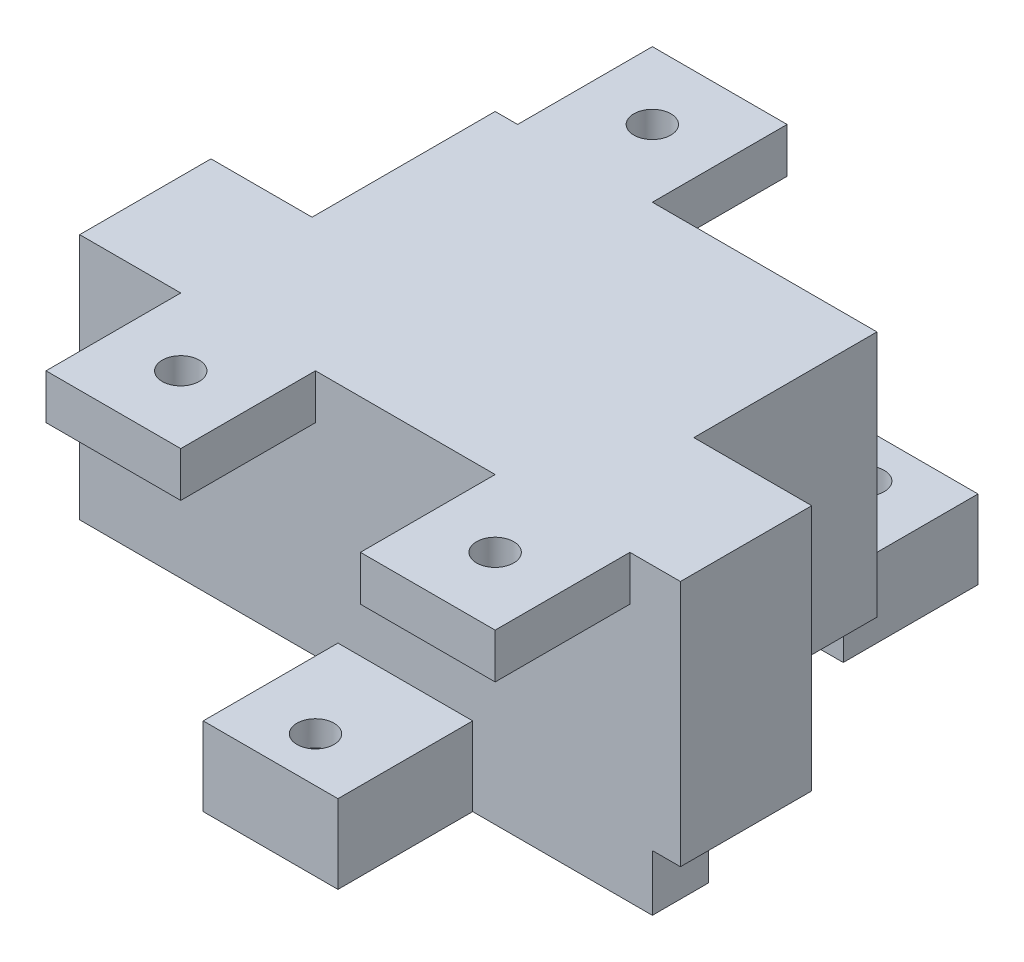
from build123d import *

# Parameters (mm, degrees)
BOSS_EXTRUDE1_DEPTH = 5
SKETCH2_W           = 14
SKETCH2_H           = 11.693793348
SKETCH2_W_2         = 9
SKETCH2_H_2         = 16.306206652
SKETCH2_W_3         = 13
SKETCH2_H_3         = 6.693793348
SKETCH2_W_4         = 8
SKETCH2_H_4         = 5
BOSS_EXTRUDE2_DEPTH = 22
BOSS_EXTRUDE3_START = -20
SKETCH3_W           = 12
SKETCH3_H           = 12
BOSS_EXTRUDE3_DEPTH = 7
CUT_EXTRUDE1_START  = -2.25
CUT_EXTRUDE1_DEPTH  = 2.5
SKETCH5_R           = 1.65
CUT_EXTRUDE3_DEPTH  = 28
SKETCH6_W           = 12
SKETCH6_H           = 12
SKETCH6_R           = 1.65
BOSS_EXTRUDE4_DEPTH = 4
BOSS_EXTRUDE6_START = -20
SKETCH7_W           = 12
SKETCH7_H           = 12
SKETCH7_R           = 1.65
BOSS_EXTRUDE6_DEPTH = 7
CUT_EXTRUDE4_START  = -2.25
CUT_EXTRUDE4_DEPTH  = 2.5
SKETCH9_W           = 12
SKETCH9_H           = 12
SKETCH9_R           = 1.65
BOSS_EXTRUDE7_DEPTH = 4


with BuildPart() as part:
    # Sketch1 → Boss-Extrude1 (new body)
    with BuildSketch(Plane(origin=(0, 0, 0), x_dir=(1, 0, 0), z_dir=(0, 1, 0))):
        Polygon((0, 0), (28, 0), (28, 5), (7, 5), (7, 23), (15, 23), (15, 28), (0, 28), align=None)
    extrude(amount=BOSS_EXTRUDE1_DEPTH)

    # Sketch2 → Boss-Extrude2 (add)
    with BuildSketch(Plane(origin=(0, 5, 0), x_dir=(1, 0, 0), z_dir=(0, 1, 0))):
        with Locations((-7, 5.846896674)):
            Rectangle(SKETCH2_W, SKETCH2_H)
        with Locations((-18.5, 5.846896674)):
            Rectangle(SKETCH2_W_2, SKETCH2_H)
        with Locations((-7, 19.846896674)):
            Rectangle(SKETCH2_W, SKETCH2_H_2)
        Polygon((7, 23), (7, 11.693793348), (20, 11.693793348), (20, 28), (15, 28), (15, 23), align=None)
        with Locations((13.5, 8.346896674)):
            Rectangle(SKETCH2_W_3, SKETCH2_H_3)
        Polygon((20, 11.693793348), (20, 5), (28, 5), (28, 0), (30.5, 0), (30.5, 11.693793348), align=None)
        Polygon((0, 11.693793348), (0, 0), (20, 0), (20, 5), (7, 5), (7, 11.693793348), align=None)
        Polygon((0, 28), (0, 11.693793348), (7, 11.693793348), (7, 23), (15, 23), (15, 28), align=None)
        with Locations((24, 2.5)):
            Rectangle(SKETCH2_W_4, SKETCH2_H_4)
    extrude(amount=BOSS_EXTRUDE2_DEPTH)

    # Sketch3 → Boss-Extrude3 (add)
    with BuildSketch(Plane(origin=(0, 27, 0), x_dir=(1, 0, 0), z_dir=(0, 1, 0)).offset(BOSS_EXTRUDE3_START)):
        with Locations((11, 34)):
            Rectangle(SKETCH3_W, SKETCH3_H)
    extrude(amount=-BOSS_EXTRUDE3_DEPTH)

    # Sketch4 → Cut-Extrude1 (cut)
    with BuildSketch(Plane.XZ.offset(CUT_EXTRUDE1_START)):
        Polygon((14.233161507, -36), (12.616580754, -33.2), (9.383419246, -33.2), (7.766838493, -36), (9.383419246, -38.8), (12.616580754, -38.8), align=None)
    extrude(amount=-CUT_EXTRUDE1_DEPTH, mode=Mode.SUBTRACT)

    # Sketch5 → Cut-Extrude3 (cut, through all)
    with BuildSketch(Plane.XZ):
        with Locations((11, -36)):
            Circle(SKETCH5_R)
    extrude(amount=-CUT_EXTRUDE3_DEPTH, mode=Mode.SUBTRACT)

    # Sketch6 → Boss-Extrude4 (add)
    with BuildSketch(Plane(origin=(0, 27, 0), x_dir=(1, 0, 0), z_dir=(0, 1, 0))):
        with Locations((-6, 34)):
            Rectangle(SKETCH6_W, SKETCH6_H)
        with Locations((-6, 34)):
            Circle(SKETCH6_R, mode=Mode.SUBTRACT)
    extrude(amount=-BOSS_EXTRUDE4_DEPTH)

    # Sketch7 → Boss-Extrude6 (add)
    with BuildSketch(Plane(origin=(0, 27, 0), x_dir=(1, 0, 0), z_dir=(0, 1, 0)).offset(BOSS_EXTRUDE6_START)):
        with Locations((6, -6)):
            Rectangle(SKETCH7_W, SKETCH7_H)
        with Locations((6, -8)):
            Circle(SKETCH7_R, mode=Mode.SUBTRACT)
    extrude(amount=-BOSS_EXTRUDE6_DEPTH)

    # Sketch8 → Cut-Extrude4 (cut)
    with BuildSketch(Plane.XZ.offset(CUT_EXTRUDE4_START)):
        Polygon((9.233161507, 8), (7.616580754, 10.8), (4.383419246, 10.8), (2.766838493, 8), (4.383419246, 5.2), (7.616580754, 5.2), align=None)
    extrude(amount=-CUT_EXTRUDE4_DEPTH, mode=Mode.SUBTRACT)

    # Sketch9 → Boss-Extrude7 (add)
    with BuildSketch(Plane(origin=(0, 27, 0), x_dir=(1, 0, 0), z_dir=(0, 1, 0))):
        with Locations((-8, -6)):
            Rectangle(SKETCH9_W, SKETCH9_H)
        with Locations((-8, -6)):
            Circle(SKETCH9_R, mode=Mode.SUBTRACT)
        with Locations((20, -6)):
            Rectangle(SKETCH9_W, SKETCH9_H)
        with Locations((20, -6)):
            Circle(SKETCH9_R, mode=Mode.SUBTRACT)
    extrude(amount=-BOSS_EXTRUDE7_DEPTH)


solid = part.part
